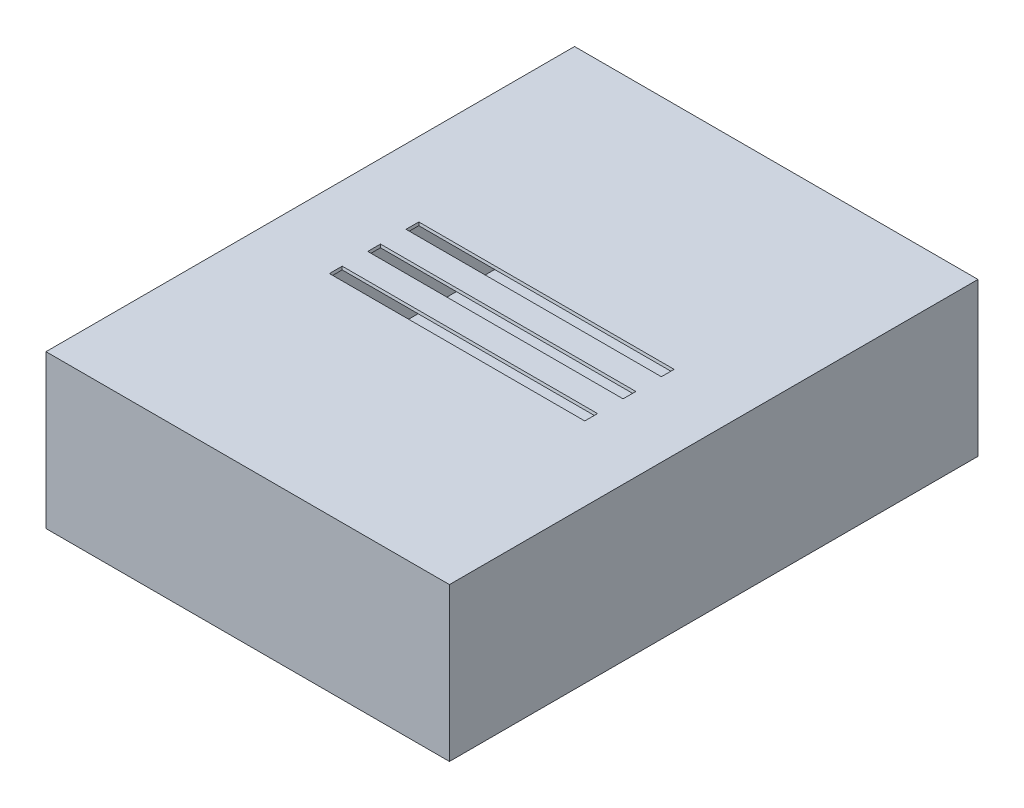
from build123d import *

# Parameters (mm, degrees)
SKETCH2_W           = 401.32
SKETCH2_H           = 152.4
BOSS_EXTRUDE1_DEPTH = 525.78
SKETCH3_W           = 396.24
SKETCH3_H           = 497.84
CUT_EXTRUDE1_DEPTH  = 149.86
SKETCH4_W           = 396.24
SKETCH4_H           = 497.84
BOSS_EXTRUDE3_DEPTH = 2.54
SKETCH8_W           = 254
SKETCH8_H           = 12.7
CUT_EXTRUDE2_DEPTH  = 2.54
CUT_EXTRUDE2_TAPER  = 15


with BuildPart() as part:
    # Sketch2 → Boss-Extrude1 (new body)
    with BuildSketch(Plane.XY):
        with Locations((200.66, 76.2)):
            Rectangle(SKETCH2_W, SKETCH2_H)
    extrude(amount=BOSS_EXTRUDE1_DEPTH)

    # Sketch3 → Cut-Extrude1 (cut)
    with BuildSketch(Plane(origin=(0, 152.4, 0), x_dir=(1, 0, 0), z_dir=(0, 1, 0))):
        with Locations((200.66, -274.32)):
            Rectangle(SKETCH3_W, SKETCH3_H)
    extrude(amount=-CUT_EXTRUDE1_DEPTH, mode=Mode.SUBTRACT)

    # Sketch4 → Boss-Extrude3 (add)
    with BuildSketch(Plane(origin=(0, 152.4, 0), x_dir=(1, 0, 0), z_dir=(0, 1, 0))):
        with Locations((200.66, -274.32)):
            Rectangle(SKETCH4_W, SKETCH4_H)
    extrude(amount=-BOSS_EXTRUDE3_DEPTH)

    # Sketch8 → Cut-Extrude2 (cut)
    with BuildSketch(Plane(origin=(0, 152.4, 0), x_dir=(1, 0, 0), z_dir=(0, 1, 0))):
        with Locations((200.66, -273.05)):
            Rectangle(SKETCH8_W, SKETCH8_H)
        with Locations((200.66, -234.95)):
            Rectangle(SKETCH8_W, SKETCH8_H)
        with Locations((200.66, -311.15)):
            Rectangle(SKETCH8_W, SKETCH8_H)
    extrude(amount=-CUT_EXTRUDE2_DEPTH, taper=CUT_EXTRUDE2_TAPER, mode=Mode.SUBTRACT)


solid = part.part
